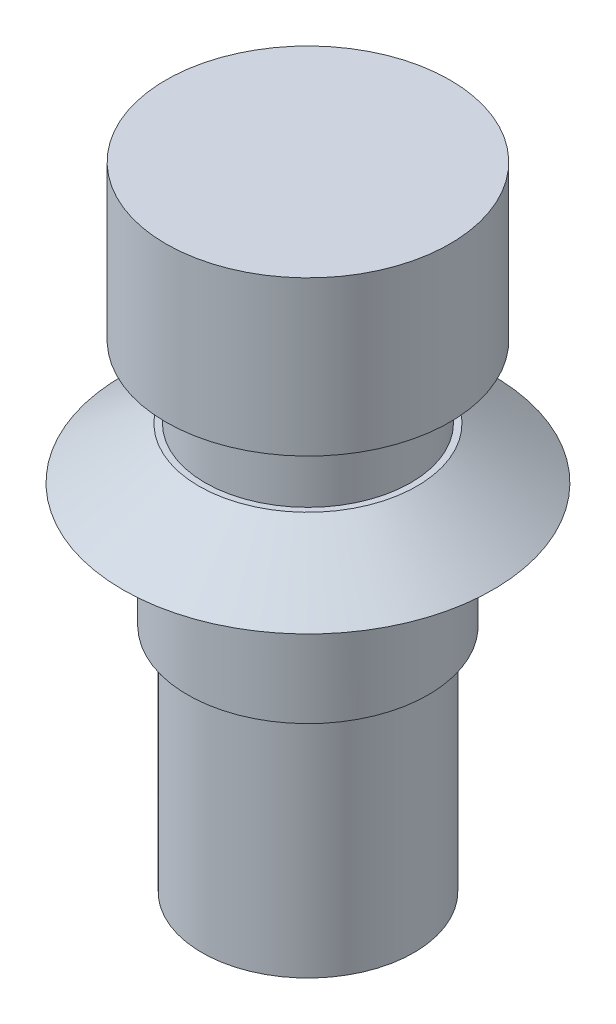
from build123d import *

# Parameters (mm, degrees)
SKETCH1_R           = 5.85
BOSS_EXTRUDE1_DEPTH = 17.2
SKETCH2_R           = 9
BOSS_EXTRUDE2_DEPTH = 2.5
BOSS_EXTRUDE2_TAPER = 56
SKETCH3_R           = 5
BOSS_EXTRUDE3_DEPTH = 3.5
SKETCH4_R           = 6.9
BOSS_EXTRUDE4_DEPTH = 7.5
SKETCH5_OUTSIDE_W   = 27.976
SKETCH5_OUTSIDE_H   = 27.976
SKETCH5_OUTSIDE_R   = 5.15
CUT_EXTRUDE1_DEPTH  = 11.2


with BuildPart() as part:
    # Sketch1 → Boss-Extrude1 (new body)
    with BuildSketch(Plane(origin=(0, 0, 0), x_dir=(1, 0, 0), z_dir=(0, 1, 0))):
        Circle(SKETCH1_R)
    extrude(amount=BOSS_EXTRUDE1_DEPTH)

    # Sketch2 → Boss-Extrude2 (add)
    with BuildSketch(Plane(origin=(0, 17.2, 0), x_dir=(1, 0, 0), z_dir=(0, 1, 0))):
        Circle(SKETCH2_R)
    extrude(amount=BOSS_EXTRUDE2_DEPTH, taper=BOSS_EXTRUDE2_TAPER)

    # Sketch3 → Boss-Extrude3 (add)
    with BuildSketch(Plane(origin=(0, 19.7, 0), x_dir=(1, 0, 0), z_dir=(0, 1, 0))):
        Circle(SKETCH3_R)
    extrude(amount=BOSS_EXTRUDE3_DEPTH)

    # Sketch4 → Boss-Extrude4 (add)
    with BuildSketch(Plane(origin=(0, 23.2, 0), x_dir=(1, 0, 0), z_dir=(0, 1, 0))):
        Circle(SKETCH4_R)
    extrude(amount=BOSS_EXTRUDE4_DEPTH)

    # Sketch5 outside → Cut-Extrude1 (cut)
    with BuildSketch(Plane.XZ):
        Rectangle(SKETCH5_OUTSIDE_W, SKETCH5_OUTSIDE_H)
        Circle(SKETCH5_OUTSIDE_R, mode=Mode.SUBTRACT)
    extrude(amount=-CUT_EXTRUDE1_DEPTH, mode=Mode.SUBTRACT)


solid = part.part
